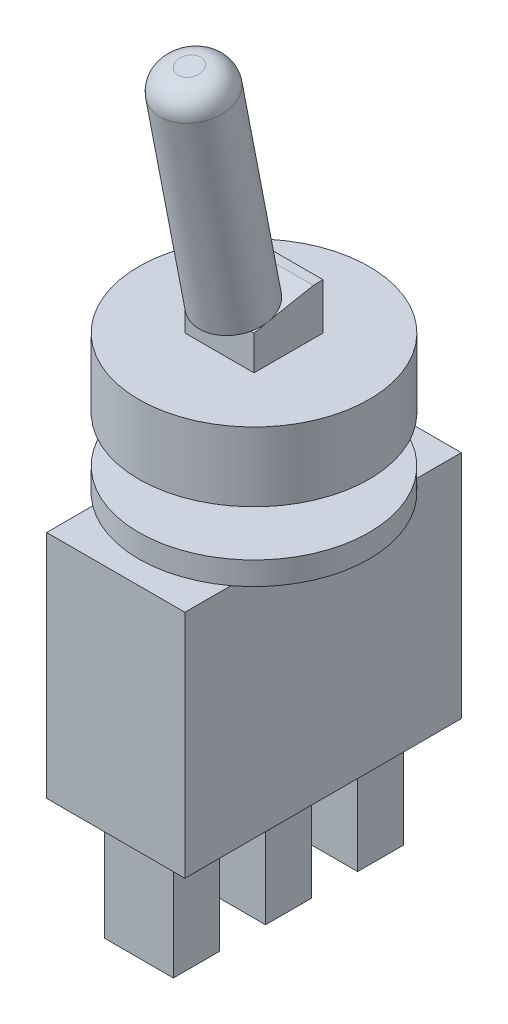
from build123d import *

# Parameters (mm, degrees)
ESQUISSE1_R      = 5
EXTRUSION1_DEPTH = 3
ESQUISSE3_R      = 2
EXTRUSION3_DEPTH = 2
ESQUISSE4_R      = 5
EXTRUSION4_DEPTH = 1
ESQUISSE5_W      = 6
ESQUISSE5_H      = 12
EXTRUSION5_DEPTH = 10
ESQUISSE6_W      = 3
ESQUISSE6_H      = 2
EXTRUSION6_DEPTH = 5
ESQUISSE8_W      = 3
ESQUISSE8_H      = 3
EXTRUSION8_DEPTH = 2
CHANFREIN1_SIZE  = 0.5
CHANFREIN1_SIZE2 = 2.572277008
ESQUISSE9_R      = 1.5
EXTRUSION9_DEPTH = 10
CONG_1_R         = 1


with BuildPart() as part:
    # Esquisse1 → Extrusion1 (new body)
    with BuildSketch(Plane(origin=(0, 0, 0), x_dir=(1, 0, 0), z_dir=(0, 1, 0))):
        Circle(ESQUISSE1_R)
    extrude(amount=EXTRUSION1_DEPTH)

    # Esquisse3 → Extrusion3 (add)
    with BuildSketch(Plane.XZ):
        Circle(ESQUISSE3_R)
    extrude(amount=EXTRUSION3_DEPTH)

    # Esquisse4 → Extrusion4 (add)
    with BuildSketch(Plane.XZ.offset(2)):
        Circle(ESQUISSE4_R)
    extrude(amount=EXTRUSION4_DEPTH)

    # Esquisse5 → Extrusion5 (add)
    with BuildSketch(Plane.XZ.offset(3)):
        Rectangle(ESQUISSE5_W, ESQUISSE5_H)
    extrude(amount=EXTRUSION5_DEPTH)

    # Esquisse6 → Extrusion6 (add)
    with BuildSketch(Plane.XZ.offset(13)):
        with Locations((0, 4)):
            Rectangle(ESQUISSE6_W, ESQUISSE6_H)
        Rectangle(ESQUISSE6_W, ESQUISSE6_H)
        with Locations((0, -4)):
            Rectangle(ESQUISSE6_W, ESQUISSE6_H)
    extrude(amount=EXTRUSION6_DEPTH)

    # Esquisse8 → Extrusion8 (add)
    with BuildSketch(Plane(origin=(0, 3, 0), x_dir=(-1, 0, 0), z_dir=(0, 1, 0))):
        Rectangle(ESQUISSE8_W, ESQUISSE8_H)
    extrude(amount=EXTRUSION8_DEPTH)

    # Chanfrein1
    chanfrein1_edges = [part.edges().sort_by_distance(p)[0] for p in [
        (0, 5, 1.5),
    ]]
    chanfrein1_side = [part.faces().sort_by_distance(p)[0] for p in [
        (0, 4, 1.5),
    ]]
    chamfer(chanfrein1_edges, length=CHANFREIN1_SIZE, length2=CHANFREIN1_SIZE2, reference=chanfrein1_side[0])

    # Esquisse9 → Extrusion9 (add)
    with BuildSketch(Plane(origin=(0, 4.617118618, 0.897476944), x_dir=(-1, 0, 0), z_dir=(0, 0.981627183, 0.190808995))):
        Circle(ESQUISSE9_R)
    extrude(amount=EXTRUSION9_DEPTH)

    # Congé1
    cong_1_edges = [part.edges().sort_by_distance(p)[0] for p in [
        (1.5, 14.433390452, 2.805566898),
    ]]
    fillet(cong_1_edges, radius=CONG_1_R)


solid = part.part
